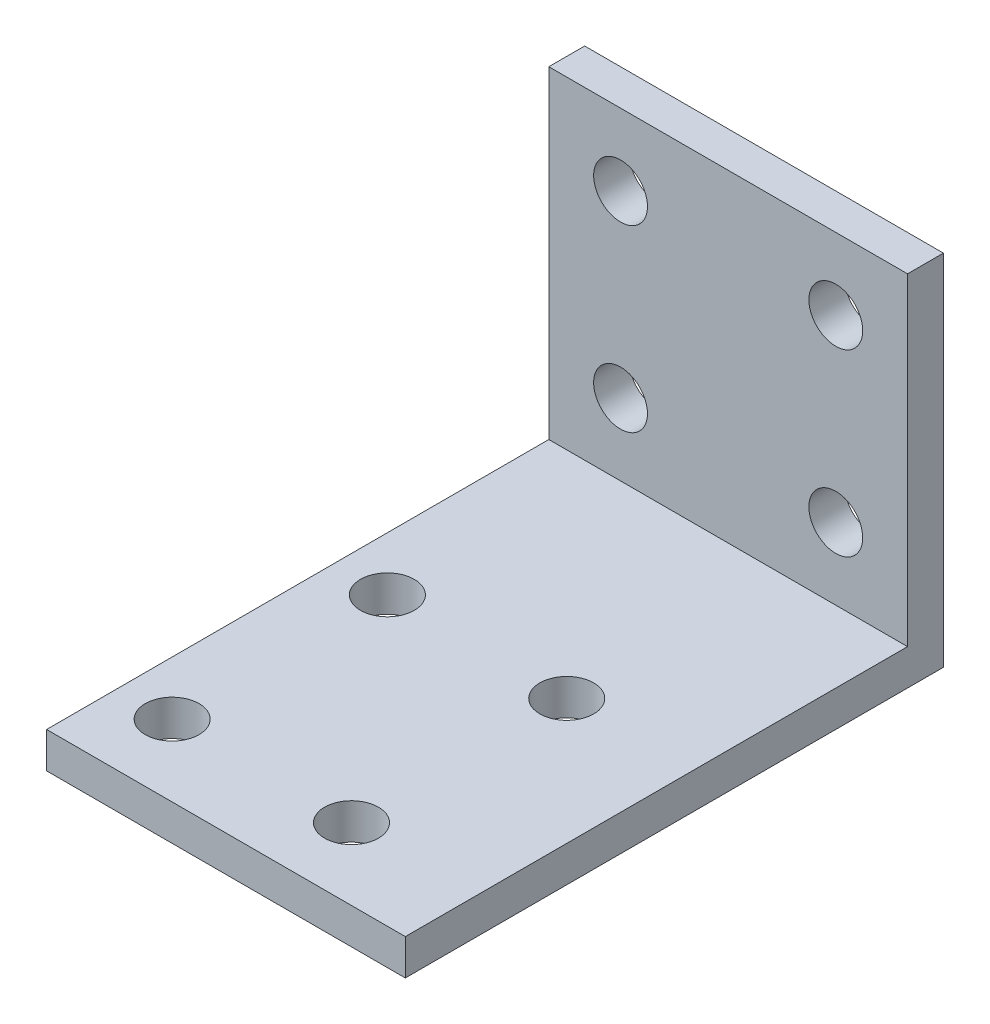
from build123d import *

# Parameters (mm, degrees)
SKETCH_1_W          = 30
SKETCH_1_H          = 40
EXTRUDE_1_DEPTH     = 3
SKETCH_2_W          = 30
SKETCH_2_H          = 3
EXTRUDE_2_DEPTH     = 17
SKETCH_5_W          = 37
SKETCH_5_H          = 3
CUT_EXTRUDE_3_DEPTH = 10
SKETCH_6_W          = 20
SKETCH_6_H          = 3
CUT_EXTRUDE_4_DEPTH = 10
SKETCH_7_W          = 20
SKETCH_7_H          = 17
CUT_EXTRUDE_5_DEPTH = 1
SKETCH_8_W          = 20
SKETCH_8_H          = 28
CUT_EXTRUDE_6_DEPTH = 1
SKETCH_10_R         = 1.5
CUT_EXTRUDE_7_DEPTH = 10
SKETCH_11_R         = 1.5
CUT_EXTRUDE_8_DEPTH = 10


with BuildPart() as part:
    # 草图1 → 凸台-拉伸1 (new body)
    with BuildSketch(Plane(origin=(0, 0, 0), x_dir=(1, 0, 0), z_dir=(0, 1, 0))):
        with Locations((-6.335311573, -13.086053412)):
            Rectangle(SKETCH_1_W, SKETCH_1_H)
    extrude(amount=EXTRUDE_1_DEPTH)

    # 草图2 → 凸台-拉伸2 (add)
    with BuildSketch(Plane(origin=(0, 3, 0), x_dir=(1, 0, 0), z_dir=(0, 1, 0))):
        with Locations((-6.335311573, 5.413946588)):
            Rectangle(SKETCH_2_W, SKETCH_2_H)
    extrude(amount=EXTRUDE_2_DEPTH)

    # 草图5 → 切除-拉伸3 (cut)
    with BuildSketch(Plane(origin=(8.664688427, 0, 0), x_dir=(0, 0, -1), z_dir=(1, 0, 0))):
        Polygon((6.913946588, 20), (3.913946588, 20), (3.913946588, 3), (3.913946588, 0), (6.913946588, 0), align=None)
        with Locations((-14.586053412, 1.5)):
            Rectangle(SKETCH_5_W, SKETCH_5_H)
    extrude(amount=-CUT_EXTRUDE_3_DEPTH, mode=Mode.SUBTRACT)

    # 草图6 → 切除-拉伸4 (cut)
    with BuildSketch(Plane.XY.offset(33.086053412)):
        with Locations((-11.335311573, 1.5)):
            Rectangle(SKETCH_6_W, SKETCH_6_H)
    extrude(amount=-CUT_EXTRUDE_4_DEPTH, mode=Mode.SUBTRACT)

    # 草图7 → 切除-拉伸5 (cut)
    with BuildSketch(Plane.XY.offset(-3.913946588)):
        with Locations((-11.335311573, 11.5)):
            Rectangle(SKETCH_7_W, SKETCH_7_H)
    extrude(amount=-CUT_EXTRUDE_5_DEPTH, mode=Mode.SUBTRACT)

    # 草图8 → 切除-拉伸6 (cut)
    with BuildSketch(Plane(origin=(0, 3, 0), x_dir=(1, 0, 0), z_dir=(0, 1, 0))):
        with Locations((-11.335311573, -9.086053412)):
            Rectangle(SKETCH_8_W, SKETCH_8_H)
    extrude(amount=-CUT_EXTRUDE_6_DEPTH, mode=Mode.SUBTRACT)

    # 草图10 → 切除-拉伸7 (cut)
    with BuildSketch(Plane.XZ):
        with Locations((-8.335311573, 7.086053412)):
            Circle(SKETCH_10_R)
        with Locations((-8.335311573, 19.086053412)):
            Circle(SKETCH_10_R)
        with Locations((-18.335311573, 7.086053412)):
            Circle(SKETCH_10_R)
        with Locations((-18.335311573, 19.086053412)):
            Circle(SKETCH_10_R)
    extrude(amount=-CUT_EXTRUDE_7_DEPTH, mode=Mode.SUBTRACT)

    # 草图11 → 切除-拉伸8 (cut)
    with BuildSketch(Plane.XY.offset(-4.913946588)):
        with Locations((-5.335311573, 6)):
            Circle(SKETCH_11_R)
        with Locations((-17.335311573, 6)):
            Circle(SKETCH_11_R)
        with Locations((-5.335311573, 16)):
            Circle(SKETCH_11_R)
        with Locations((-17.335311573, 16)):
            Circle(SKETCH_11_R)
    extrude(amount=-CUT_EXTRUDE_8_DEPTH, mode=Mode.SUBTRACT)


solid = part.part
